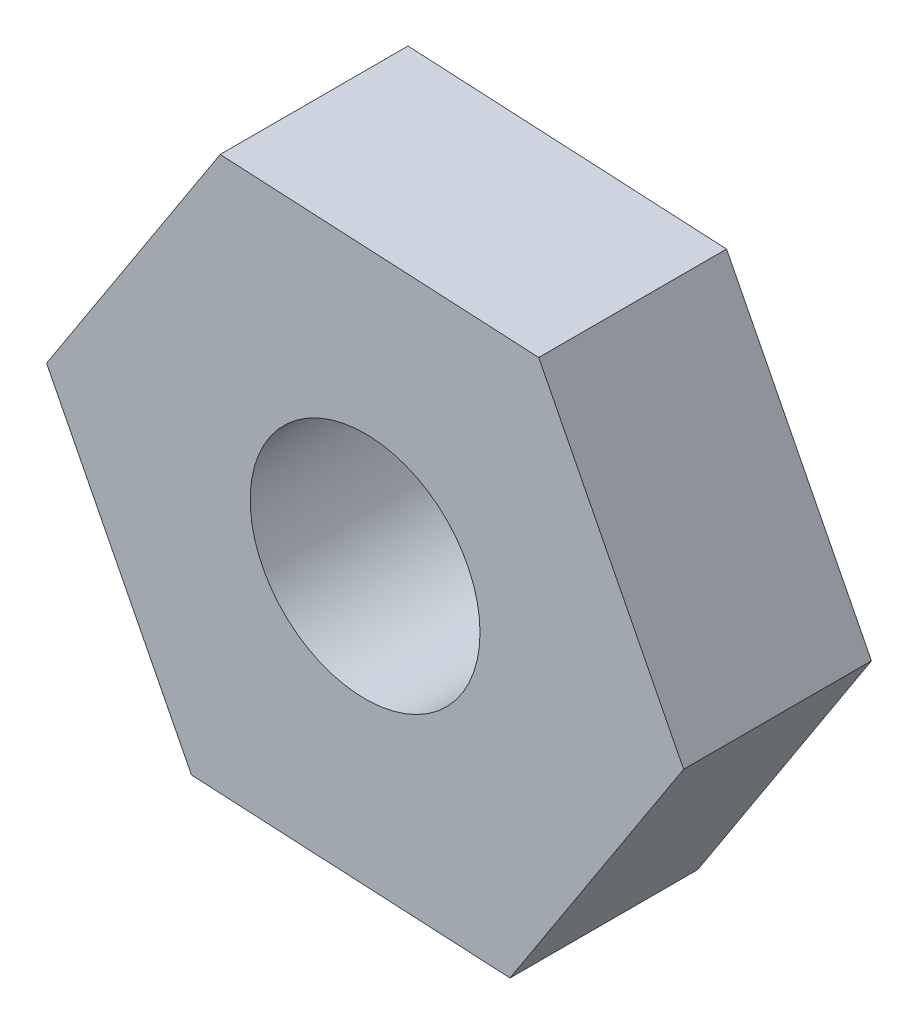
from build123d import *

# Parameters (mm, degrees)
SKETCH1_R           = 4.283438414
BOSS_EXTRUDE1_DEPTH = 7


with BuildPart() as part:
    # Sketch1 → Boss-Extrude1 (new body)
    with BuildSketch(Plane.XY):
        Polygon((5.401053743, -10.591128823), (11.872713487, -0.618114663), (6.471659745, 9.97301416), (-5.401053743, 10.591128823), (-11.872713487, 0.618114663), (-6.471659745, -9.97301416), align=None)
        Circle(SKETCH1_R, mode=Mode.SUBTRACT)
    extrude(amount=BOSS_EXTRUDE1_DEPTH)


solid = part.part
